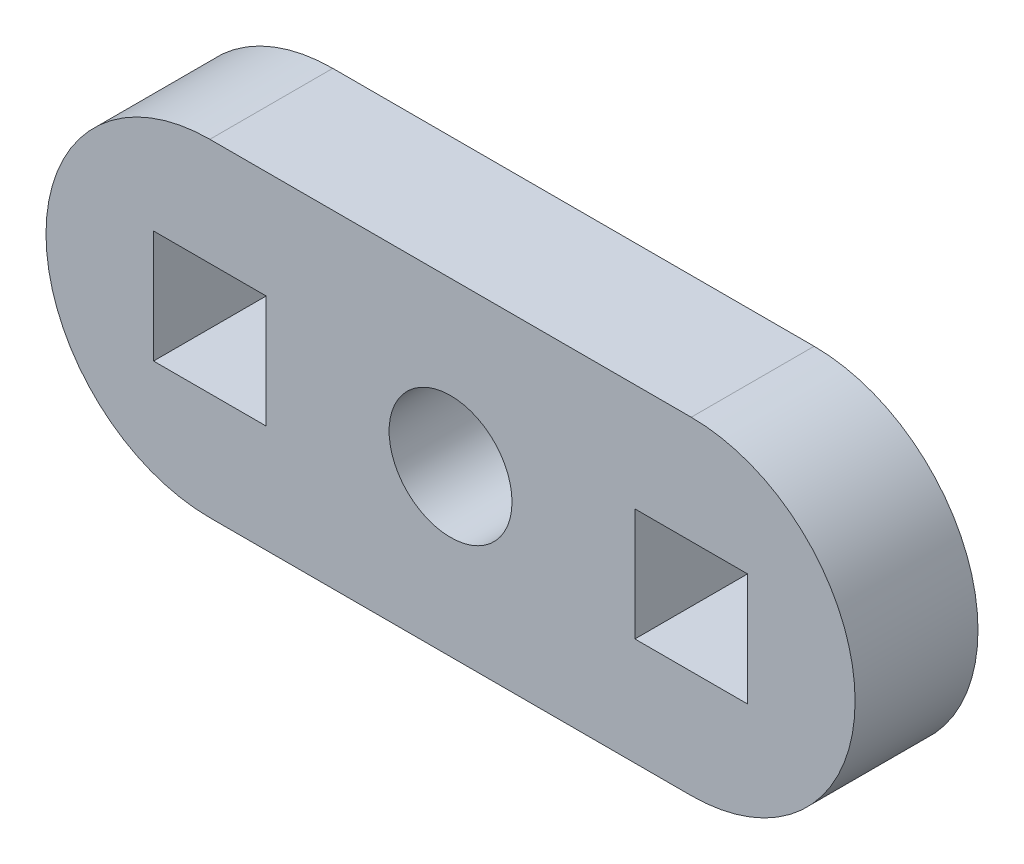
from build123d import *

# Parameters (mm, degrees)
MODEL_R             = 3
BOSS_EXTRUDE1_DEPTH = 6


with BuildPart() as part:
    # Model → Boss-Extrude1 (new body)
    with BuildSketch(Plane.XY):
        with BuildLine():
            Line((24.94501548, 21.95092931), (48.44501548, 21.95092931))
            ThreePointArc((48.44501548, 21.95092931), (56.44501548, 13.95092931), (48.44501548, 5.95092931))
            Line((48.44501548, 5.95092931), (24.94501548, 5.95092931))
            ThreePointArc((24.94501548, 5.95092931), (16.94501548, 13.95092931), (24.94501548, 21.95092931))
        make_face()
        with Locations((36.69501548, 13.993666272)):
            Circle(MODEL_R, mode=Mode.SUBTRACT)
        Polygon((27.69501548, 13.95092931), (27.69501548, 16.70092931), (22.19501548, 16.70092931), (22.19501548, 11.20092931), (27.69501548, 11.20092931), align=None, mode=Mode.SUBTRACT)
        Polygon((45.69501548, 13.95092931), (45.69501548, 16.70092931), (51.19501548, 16.70092931), (51.19501548, 11.20092931), (45.69501548, 11.20092931), align=None, mode=Mode.SUBTRACT)
    extrude(amount=BOSS_EXTRUDE1_DEPTH)


solid = part.part
